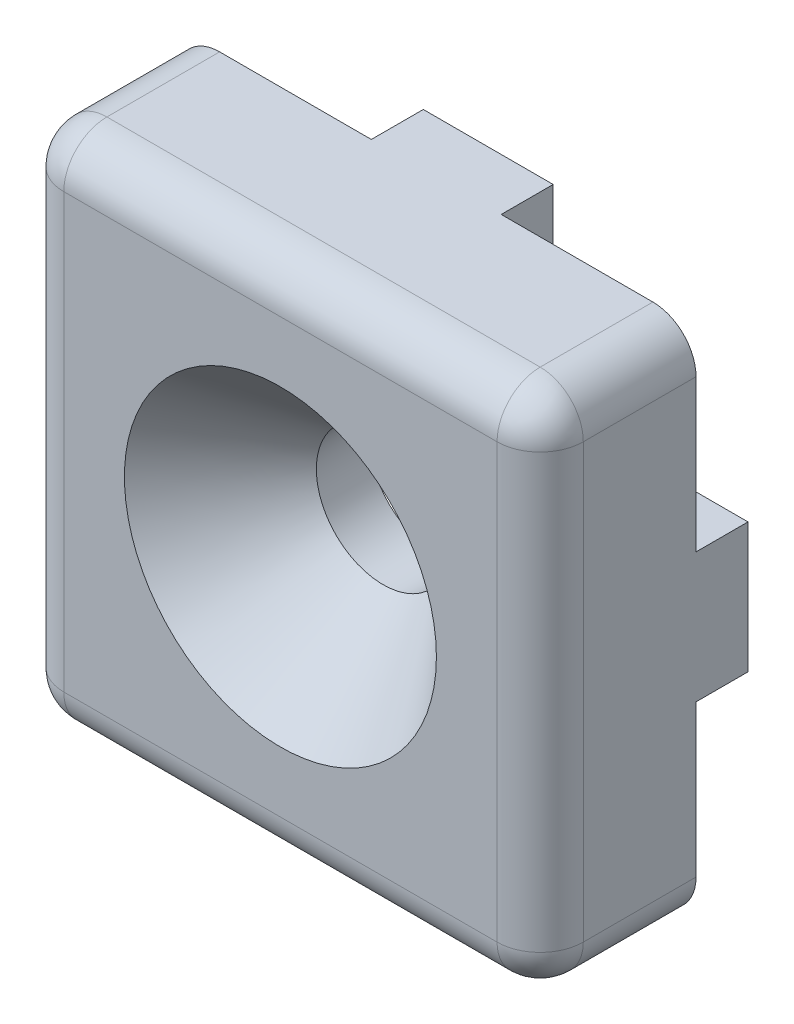
from build123d import *

# Parameters (mm, degrees)
SKETCH1_W           = 25.4
SKETCH1_H           = 25.4
BOSS_EXTRUDE1_DEPTH = 3.81
FILLET1_R           = 2.1082
SKETCH4_W           = 6.35
SKETCH4_H           = 2.54
SKETCH4_W_2         = 2.54
SKETCH4_H_2         = 6.35
BOSS_EXTRUDE2_DEPTH = 2.54


with BuildPart() as part:
    # Sketch1 → Boss-Extrude1 (new body, symmetric)
    with BuildSketch(Plane.XY):
        Rectangle(SKETCH1_W, SKETCH1_H)
    extrude(amount=BOSS_EXTRUDE1_DEPTH, both=True)

    # Sketch3 → CSK for 1/4 Flat Head Socket Cap Screw1 (revolve, cut)
    with BuildSketch(Plane(origin=(0, 0, 3.81), x_dir=(0, -1, 0), z_dir=(1, 0, 0))):
        Polygon((0, 0), (0, 7.62), (3.2639, 7.62), (3.2639, 5.019052874), (7.6268961, 0), align=None)
    revolve(axis=Axis((0, 0, 10.16), (0, 0, -1)), mode=Mode.SUBTRACT)

    # Fillet1
    fillet1_edges = [part.edges().sort_by_distance(p)[0] for p in [
        (-12.7, 0, 3.81),
        (0, -12.7, 3.81),
        (12.7, 0, 3.81),
        (12.7, -12.7, 0),
        (-12.7, -12.7, 0),
        (-12.7, 12.7, 0),
        (12.7, 12.7, 0),
        (0, 12.7, 3.81),
    ]]
    fillet(fillet1_edges, radius=FILLET1_R)

    # Sketch4 → Boss-Extrude2 (add)
    with BuildSketch(Plane(origin=(0, 0, -3.81), x_dir=(-1, 0, 0), z_dir=(0, 0, -1))):
        with Locations((0, 11.43)):
            Rectangle(SKETCH4_W, SKETCH4_H)
        with Locations((-11.43, 0)):
            Rectangle(SKETCH4_W_2, SKETCH4_H_2)
        with Locations((11.43, 0)):
            Rectangle(SKETCH4_W_2, SKETCH4_H_2)
        with Locations((0, -11.43)):
            Rectangle(SKETCH4_W, SKETCH4_H)
    extrude(amount=BOSS_EXTRUDE2_DEPTH)


solid = part.part
